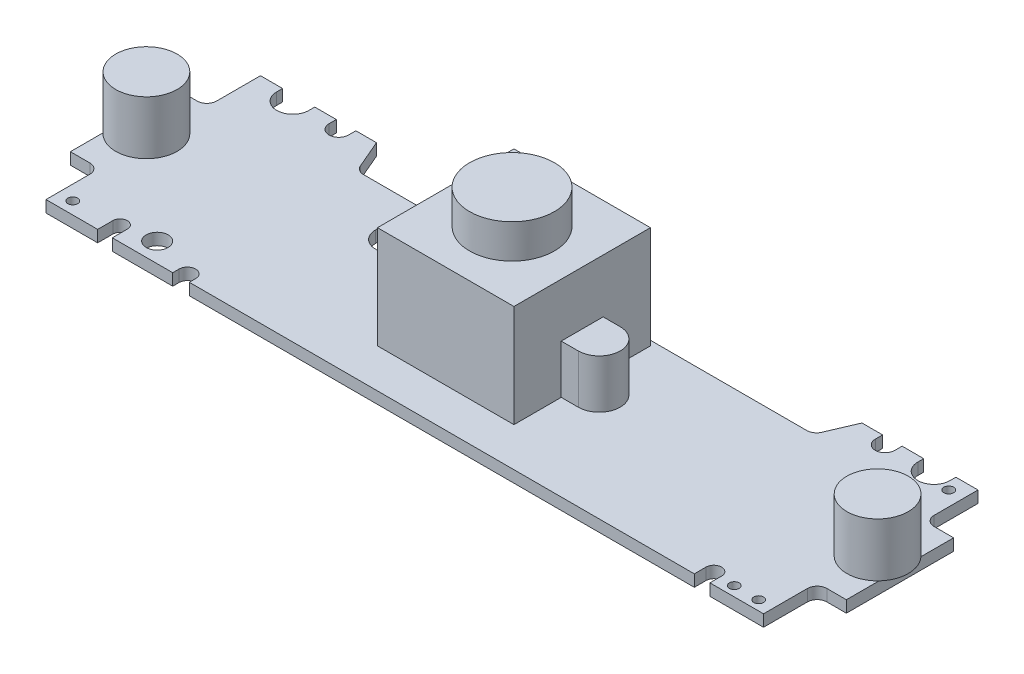
from build123d import *

# Parameters (mm, degrees)
SKETCH1_R                = 0.5
SKETCH1_R_2              = 1.125
PCB_DEPTH                = 1.2
SKETCH2_R                = 3.15
SPEAKERS_DEPTH           = 5.5
SKETCH3_W                = 14
SKETCH3_H                = 14
LENS_MOUNT_DEPTH         = 10.5
LENS_MOUTING_HOLES_DEPTH = 5
SKETCH5_R                = 4.35
LENS_DEPTH               = 3.5


with BuildPart() as part:
    # Sketch1 → PCB (new body)
    with BuildSketch(Plane(origin=(0, 0, 0), x_dir=(1, 0, 0), z_dir=(0, 1, 0))):
        with BuildLine():
            Line((-36.8, -11), (-31.5, -11))
            Line((-31.5, -11), (-31.5, -9.45))
            ThreePointArc((-31.5, -9.45), (-30.75, -8.7), (-30, -9.45))
            Line((-30, -9.45), (-30, -11))
            Line((-30, -11), (-23.8, -11))
            Line((-23.8, -11), (-23.8, -10.35))
            ThreePointArc((-23.8, -10.35), (-22.95, -9.5), (-22.1, -10.35))
            Line((-22.1, -10.35), (-22.1, -11))
            Line((-22.1, -11), (29.7, -11))
            Line((29.7, -11), (29.7, -9.8))
            ThreePointArc((29.7, -9.8), (30.5, -9), (31.3, -9.8))
            Line((31.3, -9.8), (31.3, -11))
            Line((31.3, -11), (36.8, -11))
            Line((36.8, -11), (36.8, -6.5))
            ThreePointArc((36.8, -6.5), (37.092893219, -5.792893219), (37.8, -5.5))
            Line((37.8, -5.5), (39.8, -5.5))
            Line((39.8, -5.5), (39.8, 5.5))
            Line((39.8, 5.5), (37.8, 5.5))
            ThreePointArc((37.8, 5.5), (37.092893219, 5.792893219), (36.8, 6.5))
            Line((36.8, 6.5), (36.8, 11))
            Line((36.8, 11), (34.531625915, 11))
            Line((34.531625915, 11), (34.531625915, 10.4))
            ThreePointArc((34.531625915, 10.4), (32.881625915, 8.75), (31.231625915, 10.4))
            Line((31.231625915, 10.4), (31.231625915, 11))
            Line((31.231625915, 11), (29.016759255, 11))
            Line((29.016759255, 11), (29.016759255, 10.25))
            ThreePointArc((29.016759255, 10.25), (28.016759255, 9.25), (27.016759255, 10.25))
            Line((27.016759255, 10.25), (27.016759255, 11))
            Line((27.016759255, 11), (24.9, 11))
            Line((24.9, 11), (23.659748872, 8.106080701))
            ThreePointArc((23.659748872, 8.106080701), (23.291094851, 7.665158908), (22.740603842, 7.5))
            Line((22.740603842, 7.5), (-13.8, 7.5))
            Line((-13.8, 7.5), (-13.8, 3.194222302))
            ThreePointArc((-13.8, 3.194222302), (-15.5, 1.494222302), (-17.2, 3.194222302))
            Line((-17.2, 3.194222302), (-17.2, 7.5))
            Line((-17.2, 7.5), (-22.740603842, 7.5))
            ThreePointArc((-22.740603842, 7.5), (-23.291094851, 7.665158908), (-23.659748872, 8.106080701))
            Line((-23.659748872, 8.106080701), (-24.9, 11))
            Line((-24.9, 11), (-27.016759255, 11))
            Line((-27.016759255, 11), (-27.016759255, 10.25))
            ThreePointArc((-27.016759255, 10.25), (-28.016759255, 9.25), (-29.016759255, 10.25))
            Line((-29.016759255, 10.25), (-29.016759255, 11))
            Line((-29.016759255, 11), (-31.231625915, 11))
            Line((-31.231625915, 11), (-31.231625915, 10.4))
            ThreePointArc((-31.231625915, 10.4), (-32.881625915, 8.75), (-34.531625915, 10.4))
            Line((-34.531625915, 10.4), (-34.531625915, 11))
            Line((-34.531625915, 11), (-36.8, 11))
            Line((-36.8, 11), (-36.8, 6.5))
            ThreePointArc((-36.8, 6.5), (-37.092893219, 5.792893219), (-37.8, 5.5))
            Line((-37.8, 5.5), (-39.8, 5.5))
            Line((-39.8, 5.5), (-39.8, -5.5))
            Line((-39.8, -5.5), (-37.8, -5.5))
            ThreePointArc((-37.8, -5.5), (-37.092893219, -5.792893219), (-36.8, -6.5))
            Line((-36.8, -6.5), (-36.8, -11))
        make_face()
        with Locations((35.3, 9.5)):
            Circle(SKETCH1_R, mode=Mode.SUBTRACT)
        with Locations((-35.3, -9.75)):
            Circle(SKETCH1_R, mode=Mode.SUBTRACT)
        with Locations((-27.4, -9)):
            Circle(SKETCH1_R_2, mode=Mode.SUBTRACT)
        with Locations((35.3, -10)):
            Circle(SKETCH1_R, mode=Mode.SUBTRACT)
        with Locations((32.8, -10)):
            Circle(SKETCH1_R, mode=Mode.SUBTRACT)
    extrude(amount=PCB_DEPTH)

    # Sketch2 → speakers (add)
    with BuildSketch(Plane(origin=(0, 1.2, 0), x_dir=(1, 0, 0), z_dir=(0, 1, 0))):
        with Locations((-37.5, 0)):
            Circle(SKETCH2_R)
        with Locations((37.5, 0)):
            Circle(SKETCH2_R)
    extrude(amount=SPEAKERS_DEPTH)

    # Sketch3 → lens_mount (add)
    with BuildSketch(Plane(origin=(0, 1.2, 0), x_dir=(1, 0, 0), z_dir=(0, 1, 0))):
        with Locations((0.2, 0)):
            Rectangle(SKETCH3_W, SKETCH3_H)
    extrude(amount=LENS_MOUNT_DEPTH)

    # Sketch4 → lens_mouting_holes (add)
    with BuildSketch(Plane(origin=(0, 1.2, 0), x_dir=(1, 0, 0), z_dir=(0, 1, 0))):
        with BuildLine():
            Line((-8.55, 2.15), (8.95, 2.15))
            ThreePointArc((8.95, 2.15), (11.1, 0), (8.95, -2.15))
            Line((8.95, -2.15), (-8.55, -2.15))
            ThreePointArc((-8.55, -2.15), (-10.7, 0), (-8.55, 2.15))
        make_face()
    extrude(amount=LENS_MOUTING_HOLES_DEPTH)

    # Sketch5 → lens (add)
    with BuildSketch(Plane(origin=(0, 11.7, 0), x_dir=(1, 0, 0), z_dir=(0, 1, 0))):
        Circle(SKETCH5_R)
    extrude(amount=LENS_DEPTH)


solid = part.part
